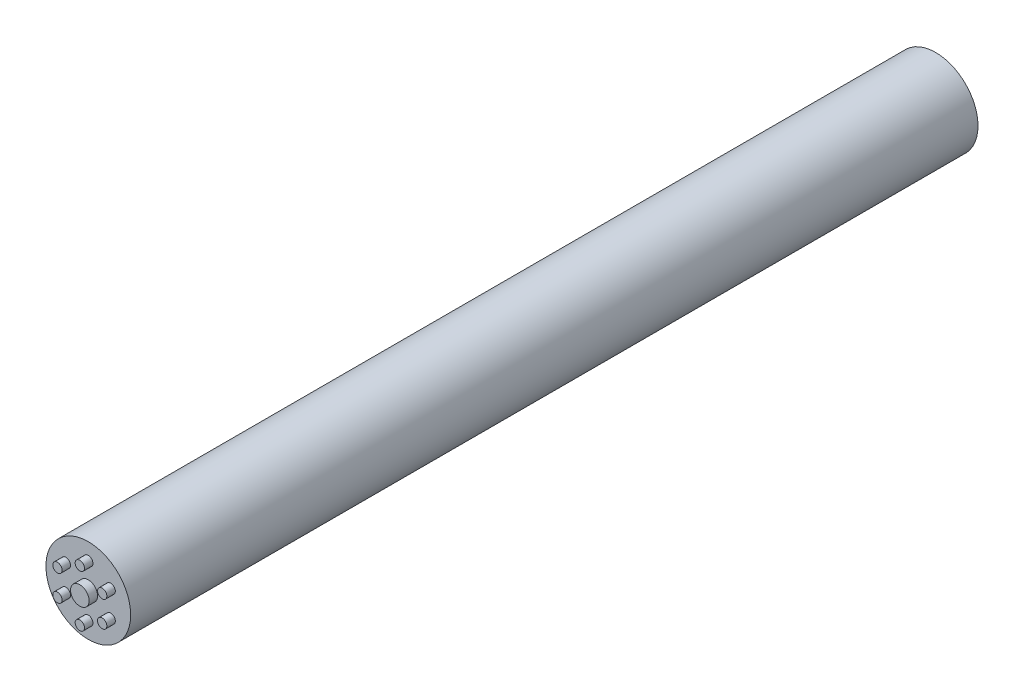
from build123d import *

# Parameters (mm, degrees)
SKETCH1_R           = 5
BOSS_EXTRUDE1_DEPTH = 100
SKETCH3_R           = 1.1
SKETCH3_R_2         = 0.55
BOSS_EXTRUDE3_DEPTH = 1


with BuildPart() as part:
    # Sketch1 → Boss-Extrude1 (new body)
    with BuildSketch(Plane.XY):
        Circle(SKETCH1_R)
    extrude(amount=BOSS_EXTRUDE1_DEPTH)

    # Sketch3 → Boss-Extrude3 (add)
    with BuildSketch(Plane.XY.offset(100)):
        Circle(SKETCH3_R)
        with Locations((-2.642220318, 1.525486612)):
            Circle(SKETCH3_R_2)
        with Locations((0, 3.050973223)):
            Circle(SKETCH3_R_2)
        with Locations((-2.642220318, -1.525486612)):
            Circle(SKETCH3_R_2)
        with Locations((0, -3.050973223)):
            Circle(SKETCH3_R_2)
        with Locations((2.642220318, -1.525486612)):
            Circle(SKETCH3_R_2)
        with Locations((2.642220318, 1.525486612)):
            Circle(SKETCH3_R_2)
    extrude(amount=BOSS_EXTRUDE3_DEPTH)


solid = part.part
